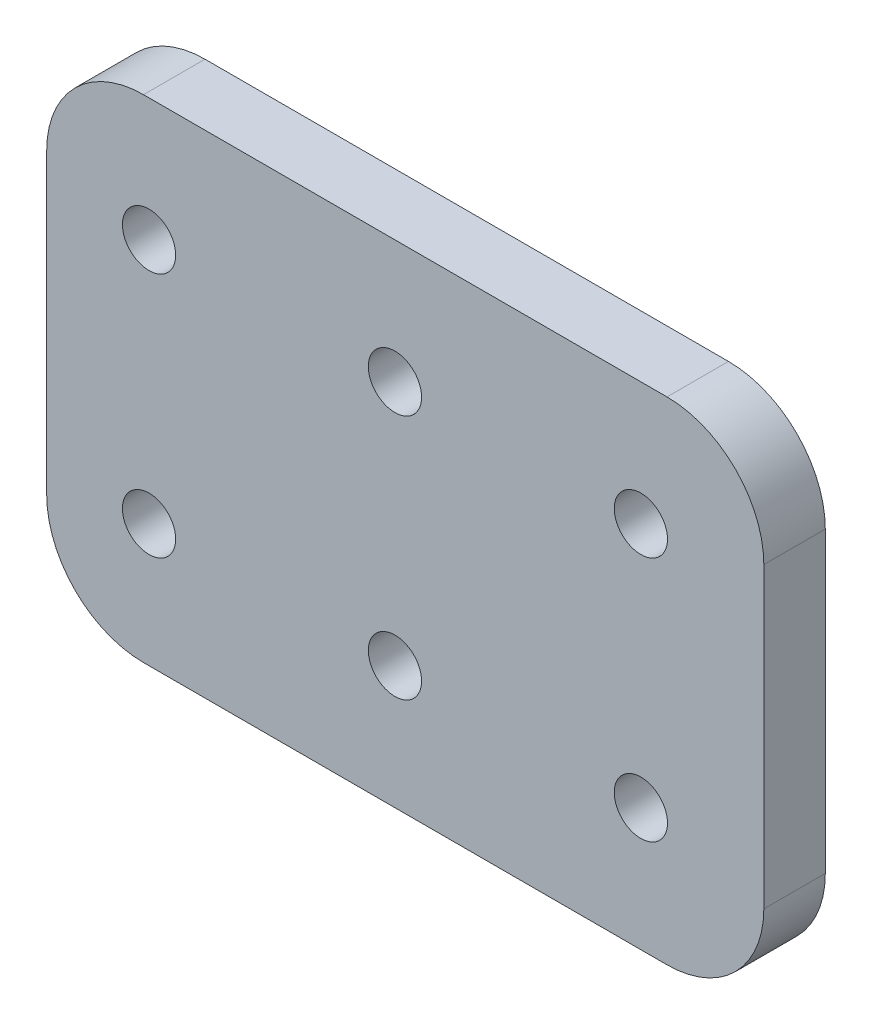
from build123d import *

# Parameters (mm, degrees)
SKETCH1_W            = 74.07
SKETCH1_H            = 50.8
BOSS_EXTRUDE1_DEPTH  = 6.35
FILLET1_R            = 10
M5_CLEARANCE_HOLE1_D = 5.5


with BuildPart() as part:
    # Sketch1 → Boss-Extrude1 (new body)
    with BuildSketch(Plane.XY):
        Rectangle(SKETCH1_W, SKETCH1_H)
    extrude(amount=BOSS_EXTRUDE1_DEPTH)

    # Fillet1
    fillet1_edges = [part.edges().sort_by_distance(p)[0] for p in [
        (-37.035, 25.4, 3.175),
        (37.035, 25.4, 3.175),
        (37.035, -25.4, 3.175),
        (-37.035, -25.4, 3.175),
    ]]
    fillet(fillet1_edges, radius=FILLET1_R)

    # M5 Clearance Hole1 (through all)
    with Locations(Plane.XY.offset(6.35)):
        with Locations((-26.465, 12.7), (-26.465, -12.7), (-1.065, -12.7), (-1.065, 12.7), (24.335, 12.7), (24.335, -12.7)):
            Hole(M5_CLEARANCE_HOLE1_D / 2)


solid = part.part
